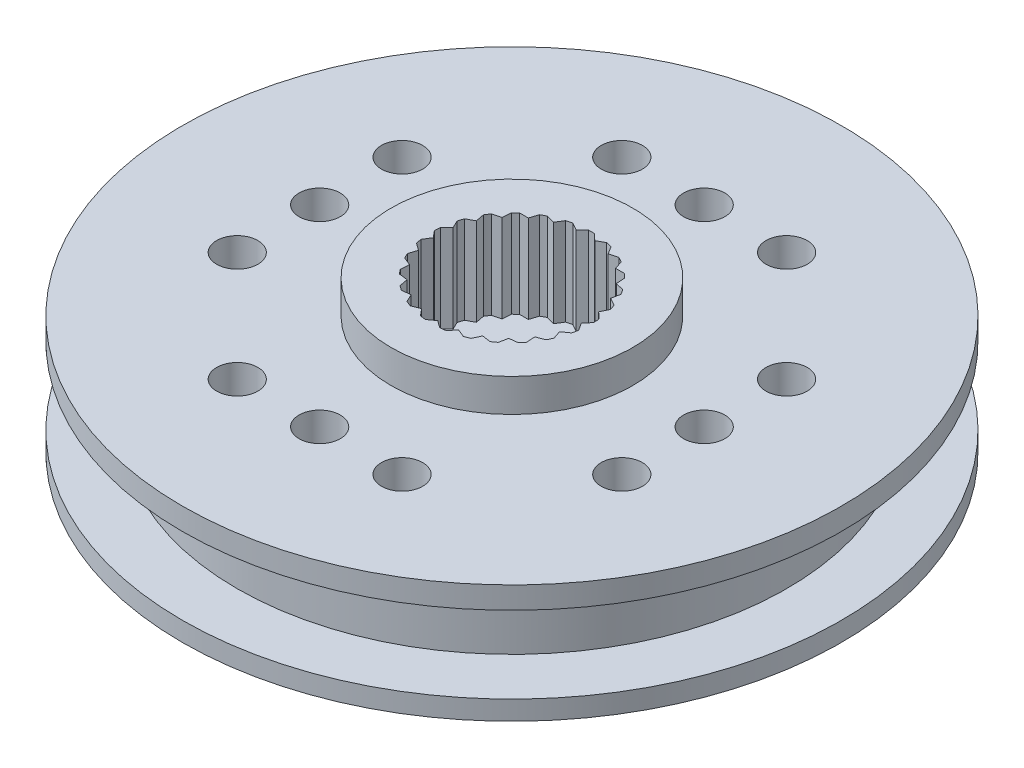
from build123d import *

# Parameters (mm, degrees)
SKETCH2_R               = 6
SKETCH2_R_2             = 1.5
BOSS_EXTRUDE1_DEPTH     = 1.15
SKETCH3_R               = 4.4
BOSS_EXTRUDE2_DEPTH     = 3.2
SKETCH5_R               = 10
SKETCH5_R_2             = 0.75
SKETCH5_R_3             = 1.5
BOSS_EXTRUDE4_DEPTH     = 1.15
ENL_V_START             = -0.6
ESQUISSE4_R             = 10
ESQUISSE4_R_2           = 9
ENL_V_MAT_EXTRU_1_DEPTH = 1
ESQUISSE5_R             = 11.998569968
ESQUISSE5_R_2           = 10
BOSS_EXTRU_1_DEPTH      = 0.55
BOSS_EXTRU_2_START      = -1.6
ESQUISSE5_3_R           = 11.998569968
ESQUISSE5_3_R_2         = 10
BOSS_EXTRU_2_DEPTH      = 0.7
ESQUISSE5_4_R           = 11.998569968
ESQUISSE5_4_R_2         = 10
BOSS_EXTRU_3_DEPTH      = 0.6
ESQUISSE6_R             = 11
ESQUISSE6_R_2           = 9.794741115
BOSS_EXTRU_4_DEPTH      = 1.6
BOSS_EXTRU_5_START      = 2
ESQUISSE7_R             = 11.998569968
ESQUISSE7_R_2           = 4.4
BOSS_EXTRU_5_DEPTH      = 2
ENL_V_START_2           = 1.2
ESQUISSE8_R             = 11.998569968
ESQUISSE8_R_2           = 11
ENL_V_MAT_EXTRU_2_DEPTH = 2.2
ENL_V_START_3           = 10
ESQUISSE9_R             = 0.75
ENL_V_MAT_EXTRU_3_DEPTH = 32.2
ESQUISSE10_R            = 11.998569968
ESQUISSE10_R_2          = 10.005168165
ENL_V_MAT_EXTRU_4_DEPTH = 2.8


with BuildPart() as part:
    # Sketch2 → Boss-Extrude1 (new, symmetric)
    with BuildSketch(Plane(origin=(0, 0, 0), x_dir=(1, 0, 0), z_dir=(0, 1, 0))):
        Circle(SKETCH2_R)
        Circle(SKETCH2_R_2, mode=Mode.SUBTRACT)
    extrude(amount=BOSS_EXTRUDE1_DEPTH, both=True)

    # Sketch3 → Boss-Extrude2 (add)
    with BuildSketch(Plane(origin=(0, 1.15, 0), x_dir=(1, 0, 0), z_dir=(0, 1, 0))):
        Circle(SKETCH3_R)
        with BuildLine():
            Line((0.107421435, 2.898009771), (0.338399731, 2.678709694))
            Line((0.338399731, 2.678709694), (0.61665913, 2.83367809))
            ThreePointArc((0.61665913, 2.83367809), (0.721200673, 2.808891167), (0.824752316, 2.780248841))
            Line((0.824752316, 2.780248841), (0.993936292, 2.510396512))
            Line((0.993936292, 2.510396512), (1.301992734, 2.591295993))
            ThreePointArc((1.301992734, 2.591295993), (1.397085655, 2.541289372), (1.490260976, 2.48779465))
            Line((1.490260976, 2.48779465), (1.587020181, 2.184345885))
            Line((1.587020181, 2.184345885), (1.905517346, 2.186093238))
            ThreePointArc((1.905517346, 2.186093238), (1.985186607, 2.11400902), (2.062131058, 2.039023173))
            Line((2.062131058, 2.039023173), (2.080385755, 1.721044772))
            Line((2.080385755, 1.721044772), (2.389311295, 1.643530205))
            ThreePointArc((2.389311295, 1.643530205), (2.448550984, 1.553897705), (2.504429862, 1.46213237))
            Line((2.504429862, 1.46213237), (2.443033042, 1.149604087))
            Line((2.443033042, 1.149604087), (2.722976028, 0.997698125))
            ThreePointArc((2.722976028, 0.997698125), (2.758063897, 0.896149284), (2.789366126, 0.793370413))
            Line((2.789366126, 0.793370413), (2.652175577, 0.505929549))
            Line((2.652175577, 0.505929549), (2.885546163, 0.289177003))
            ThreePointArc((2.885546163, 0.289177003), (2.894277512, 0.182092507), (2.899036259, 0.074758075))
            Line((2.899036259, 0.074758075), (2.694672167, -0.169534403))
            Line((2.694672167, -0.169534403), (2.866806821, -0.437514174))
            ThreePointArc((2.866806821, -0.437514174), (2.848633027, -0.543405812), (2.826549281, -0.648551587))
            Line((2.826549281, -0.648551587), (2.567852594, -0.834345885))
            Line((2.567852594, -0.834345885), (2.667935462, -1.136714727))
            ThreePointArc((2.667935462, -1.136714727), (2.623998452, -1.234759946), (2.576459817, -1.331110368))
            Line((2.576459817, -1.331110368), (2.279685399, -1.446732346))
            Line((2.279685399, -1.446732346), (2.301427906, -1.764491312))
            ThreePointArc((2.301427906, -1.764491312), (2.234488404, -1.84852957), (2.164481907, -1.930030589))
            Line((2.164481907, -1.930030589), (1.848277186, -1.968215294))
            Line((1.848277186, -1.968215294), (1.790313171, -2.281398419))
            ThreePointArc((1.790313171, -2.281398419), (1.704577232, -2.346149284), (1.616501638, -2.40767989))
            Line((1.616501638, -2.40767989), (1.30073492, -2.366028036))
            Line((1.30073492, -2.366028036), (1.166706475, -2.654956874))
            ThreePointArc((1.166706475, -2.654956874), (1.067561203, -2.696351809), (0.966950626, -2.734045809))
            Line((0.966950626, -2.734045809), (0.671462695, -2.615174535))
            Line((0.671462695, -2.615174535), (0.469791321, -2.861694623))
            ThreePointArc((0.469791321, -2.861694623), (0.363466377, -2.877132634), (0.25664255, -2.888621575))
            Line((0.25664255, -2.888621575), (0, -2.7))
            Line((0, -2.7), (-0.25664255, -2.888621575))
            ThreePointArc((-0.25664255, -2.888621575), (-0.363466377, -2.877132634), (-0.469791321, -2.861694623))
            Line((-0.469791321, -2.861694623), (-0.671462695, -2.615174535))
            Line((-0.671462695, -2.615174535), (-0.966950626, -2.734045809))
            ThreePointArc((-0.966950626, -2.734045809), (-1.067561203, -2.696351809), (-1.166706475, -2.654956874))
            Line((-1.166706475, -2.654956874), (-1.30073492, -2.366028036))
            Line((-1.30073492, -2.366028036), (-1.616501638, -2.40767989))
            ThreePointArc((-1.616501638, -2.40767989), (-1.704577232, -2.346149284), (-1.790313171, -2.281398419))
            Line((-1.790313171, -2.281398419), (-1.848277186, -1.968215294))
            Line((-1.848277186, -1.968215294), (-2.164481907, -1.930030589))
            ThreePointArc((-2.164481907, -1.930030589), (-2.234488404, -1.84852957), (-2.301427906, -1.764491312))
            Line((-2.301427906, -1.764491312), (-2.279685399, -1.446732346))
            Line((-2.279685399, -1.446732346), (-2.576459817, -1.331110368))
            ThreePointArc((-2.576459817, -1.331110368), (-2.623998452, -1.234759946), (-2.667935462, -1.136714727))
            Line((-2.667935462, -1.136714727), (-2.567852594, -0.834345885))
            Line((-2.567852594, -0.834345885), (-2.826549281, -0.648551587))
            ThreePointArc((-2.826549281, -0.648551587), (-2.848633027, -0.543405812), (-2.866806821, -0.437514174))
            Line((-2.866806821, -0.437514174), (-2.694672167, -0.169534403))
            Line((-2.694672167, -0.169534403), (-2.899036259, 0.074758075))
            ThreePointArc((-2.899036259, 0.074758075), (-2.894277512, 0.182092507), (-2.885546163, 0.289177003))
            Line((-2.885546163, 0.289177003), (-2.652175577, 0.505929549))
            Line((-2.652175577, 0.505929549), (-2.789366126, 0.793370413))
            ThreePointArc((-2.789366126, 0.793370413), (-2.758063897, 0.896149284), (-2.722976028, 0.997698125))
            Line((-2.722976028, 0.997698125), (-2.443033042, 1.149604087))
            Line((-2.443033042, 1.149604087), (-2.504429862, 1.46213237))
            ThreePointArc((-2.504429862, 1.46213237), (-2.448550984, 1.553897705), (-2.389311295, 1.643530205))
            Line((-2.389311295, 1.643530205), (-2.080385755, 1.721044772))
            Line((-2.080385755, 1.721044772), (-2.062131058, 2.039023173))
            ThreePointArc((-2.062131058, 2.039023173), (-1.985186607, 2.11400902), (-1.905517346, 2.186093238))
            Line((-1.905517346, 2.186093238), (-1.587020181, 2.184345885))
            Line((-1.587020181, 2.184345885), (-1.490260976, 2.48779465))
            ThreePointArc((-1.490260976, 2.48779465), (-1.397085655, 2.541289372), (-1.301992734, 2.591295993))
            Line((-1.301992734, 2.591295993), (-0.993936292, 2.510396512))
            Line((-0.993936292, 2.510396512), (-0.824752316, 2.780248841))
            ThreePointArc((-0.824752316, 2.780248841), (-0.721200673, 2.808891167), (-0.61665913, 2.83367809))
            Line((-0.61665913, 2.83367809), (-0.338399731, 2.678709694))
            Line((-0.338399731, 2.678709694), (-0.107421435, 2.898009771))
            ThreePointArc((-0.107421435, 2.898009771), (0, 2.9), (0.107421435, 2.898009771))
        make_face(mode=Mode.SUBTRACT)
    extrude(amount=BOSS_EXTRUDE2_DEPTH)

    # Sketch5 → Boss-Extrude4 (add, symmetric)
    with BuildSketch(Plane(origin=(0, 0, 0), x_dir=(1, 0, 0), z_dir=(0, 1, 0))):
        Circle(SKETCH5_R)
        with Locations((0, 7)):
            Circle(SKETCH5_R_2, mode=Mode.SUBTRACT)
        with Locations((-3, 7)):
            Circle(SKETCH5_R_2, mode=Mode.SUBTRACT)
        with Locations((3, 7)):
            Circle(SKETCH5_R_2, mode=Mode.SUBTRACT)
        with Locations((7, 3)):
            Circle(SKETCH5_R_2, mode=Mode.SUBTRACT)
        with Locations((7, 0)):
            Circle(SKETCH5_R_2, mode=Mode.SUBTRACT)
        with Locations((7, -3)):
            Circle(SKETCH5_R_2, mode=Mode.SUBTRACT)
        with Locations((3, -7)):
            Circle(SKETCH5_R_2, mode=Mode.SUBTRACT)
        with Locations((0, -7)):
            Circle(SKETCH5_R_2, mode=Mode.SUBTRACT)
        with Locations((-3, -7)):
            Circle(SKETCH5_R_2, mode=Mode.SUBTRACT)
        with Locations((-7, -3)):
            Circle(SKETCH5_R_2, mode=Mode.SUBTRACT)
        with Locations((-7, 0)):
            Circle(SKETCH5_R_2, mode=Mode.SUBTRACT)
        with Locations((-7, 3)):
            Circle(SKETCH5_R_2, mode=Mode.SUBTRACT)
        Circle(SKETCH5_R_3, mode=Mode.SUBTRACT)
    extrude(amount=BOSS_EXTRUDE4_DEPTH, both=True)

    # Esquisse4 → Enlèv. mat.-Extru.1 (cut)
    with BuildSketch(Plane(origin=(0, 1.15, 0), x_dir=(1, 0, 0), z_dir=(0, 1, 0)).offset(ENL_V_START)):
        Circle(ESQUISSE4_R)
        Circle(ESQUISSE4_R_2, mode=Mode.SUBTRACT)
    extrude(amount=-ENL_V_MAT_EXTRU_1_DEPTH, mode=Mode.SUBTRACT)

    # Esquisse5 → Boss.-Extru.1 (add)
    with BuildSketch(Plane(origin=(0, 1.15, 0), x_dir=(1, 0, 0), z_dir=(0, 1, 0))):
        Circle(ESQUISSE5_R)
        Circle(ESQUISSE5_R_2, mode=Mode.SUBTRACT)
    extrude(amount=-BOSS_EXTRU_1_DEPTH)

    # Esquisse5_3 → Boss.-Extru.2 (add)
    with BuildSketch(Plane(origin=(0, 1.15, 0), x_dir=(1, 0, 0), z_dir=(0, 1, 0)).offset(BOSS_EXTRU_2_START)):
        Circle(ESQUISSE5_3_R)
        Circle(ESQUISSE5_3_R_2, mode=Mode.SUBTRACT)
    extrude(amount=-BOSS_EXTRU_2_DEPTH)

    # Esquisse5_4 → Boss.-Extru.3 (add)
    with BuildSketch(Plane(origin=(0, 1.15, 0), x_dir=(1, 0, 0), z_dir=(0, 1, 0))):
        Circle(ESQUISSE5_4_R)
        Circle(ESQUISSE5_4_R_2, mode=Mode.SUBTRACT)
    extrude(amount=-BOSS_EXTRU_3_DEPTH)

    # Esquisse6 → Boss.-Extru.4 (add)
    with BuildSketch(Plane(origin=(0, 1.15, 0), x_dir=(1, 0, 0), z_dir=(0, 1, 0))):
        Circle(ESQUISSE6_R)
        Circle(ESQUISSE6_R_2, mode=Mode.SUBTRACT)
    extrude(amount=-BOSS_EXTRU_4_DEPTH)

    # Esquisse7 → Boss.-Extru.5 (add)
    with BuildSketch(Plane(origin=(0, 1.15, 0), x_dir=(1, 0, 0), z_dir=(0, 1, 0)).offset(BOSS_EXTRU_5_START)):
        Circle(ESQUISSE7_R)
        Circle(ESQUISSE7_R_2, mode=Mode.SUBTRACT)
    extrude(amount=-BOSS_EXTRU_5_DEPTH)

    # Esquisse8 → Enlèv. mat.-Extru.2 (cut)
    with BuildSketch(Plane(origin=(0, 1.15, 0), x_dir=(1, 0, 0), z_dir=(0, 1, 0)).offset(ENL_V_START_2)):
        Circle(ESQUISSE8_R)
        Circle(ESQUISSE8_R_2, mode=Mode.SUBTRACT)
    extrude(amount=-ENL_V_MAT_EXTRU_2_DEPTH, mode=Mode.SUBTRACT)

    # Esquisse9 → Enlèv. mat.-Extru.3 (cut)
    with BuildSketch(Plane(origin=(0, -1.15, 0), x_dir=(-1, 0, 0), z_dir=(0, -1, 0)).offset(ENL_V_START_3)):
        with Locations((3, 7)):
            Circle(ESQUISSE9_R)
        with Locations((7, 3)):
            Circle(ESQUISSE9_R)
        with Locations((7, 0)):
            Circle(ESQUISSE9_R)
        with Locations((7, -3)):
            Circle(ESQUISSE9_R)
        with Locations((3, -7)):
            Circle(ESQUISSE9_R)
        with Locations((0, -7)):
            Circle(ESQUISSE9_R)
        with Locations((-3, -7)):
            Circle(ESQUISSE9_R)
        with Locations((-7, -3)):
            Circle(ESQUISSE9_R)
        with Locations((-7, 0)):
            Circle(ESQUISSE9_R)
        with Locations((-7, 3)):
            Circle(ESQUISSE9_R)
        with Locations((-3, 7)):
            Circle(ESQUISSE9_R)
        with Locations((0, 7)):
            Circle(ESQUISSE9_R)
    extrude(amount=-ENL_V_MAT_EXTRU_3_DEPTH, mode=Mode.SUBTRACT)

    # Esquisse10 → Enlèv. mat.-Extru.4 (cut)
    with BuildSketch(Plane(origin=(0, 1.15, 0), x_dir=(1, 0, 0), z_dir=(0, 1, 0)).offset(ENL_V_START_2)):
        Circle(ESQUISSE10_R)
        Circle(ESQUISSE10_R_2, mode=Mode.SUBTRACT)
    extrude(amount=-ENL_V_MAT_EXTRU_4_DEPTH, mode=Mode.SUBTRACT)


solid = part.part
